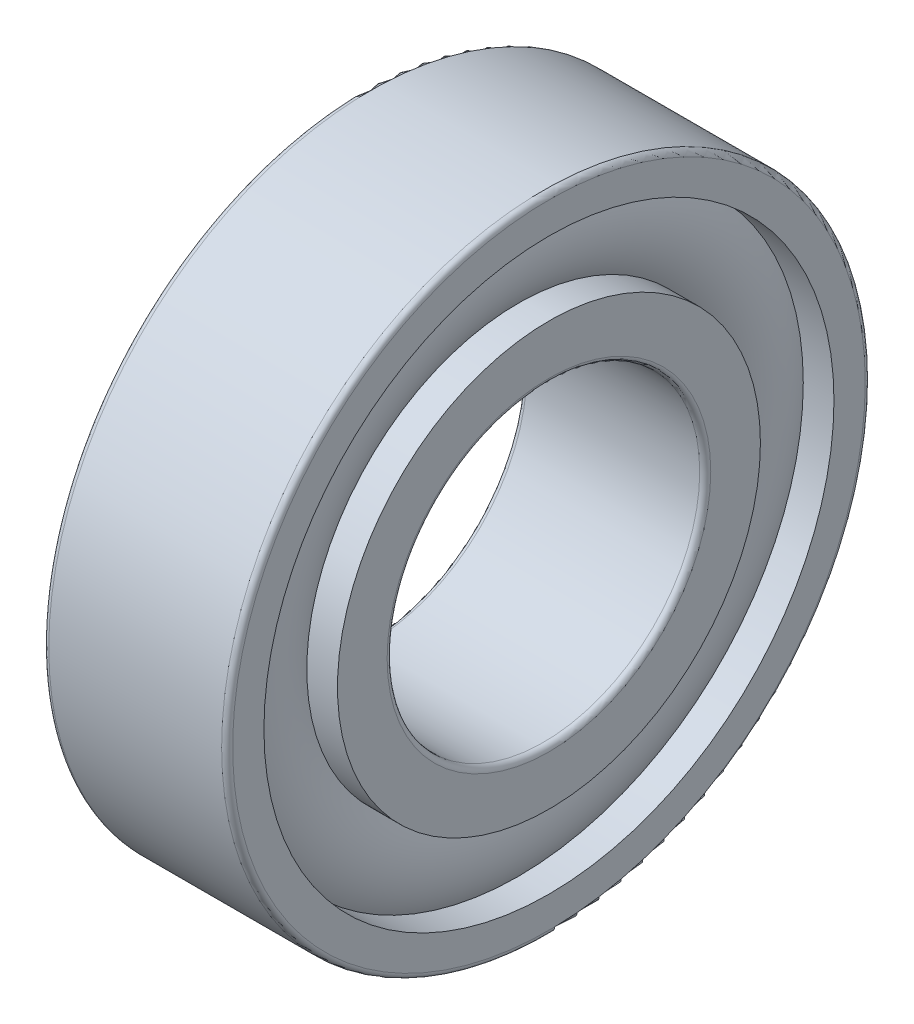
from build123d import *


with BuildPart() as part:
    # Sketch1 → Revolve1 (revolve)
    with BuildSketch(Plane.XY):
        with BuildLine():
            Line((2.65093816, 15.5), (4.319649297, 15.5))
            ThreePointArc((4.319649297, 15.5), (3.765389873, 13.5), (4.319649297, 11.5))
            Line((4.319649297, 11.5), (2.65093816, 11.5))
            Line((2.65093816, 11.5), (2.65093816, 8.8))
            ThreePointArc((2.65093816, 8.8), (2.738806126, 8.587867966), (2.95093816, 8.5))
            Line((2.95093816, 8.5), (12.35093816, 8.5))
            ThreePointArc((12.35093816, 8.5), (12.563070194, 8.587867966), (12.65093816, 8.8))
            Line((12.65093816, 8.8), (12.65093816, 11.5))
            Line((12.65093816, 11.5), (10.982227023, 11.5))
            ThreePointArc((10.982227023, 11.5), (11.536486446, 13.5), (10.982227023, 15.5))
            Line((10.982227023, 15.5), (12.65093816, 15.5))
            Line((12.65093816, 15.5), (12.65093816, 17.2))
            ThreePointArc((12.65093816, 17.2), (12.563070194, 17.412132034), (12.35093816, 17.5))
            Line((12.35093816, 17.5), (2.95093816, 17.5))
            ThreePointArc((2.95093816, 17.5), (2.738806126, 17.412132034), (2.65093816, 17.2))
            Line((2.65093816, 17.2), (2.65093816, 15.5))
        make_face()
    revolve(axis=Axis((14.7, 0, 0), (-1, 0, 0)))


solid = part.part
